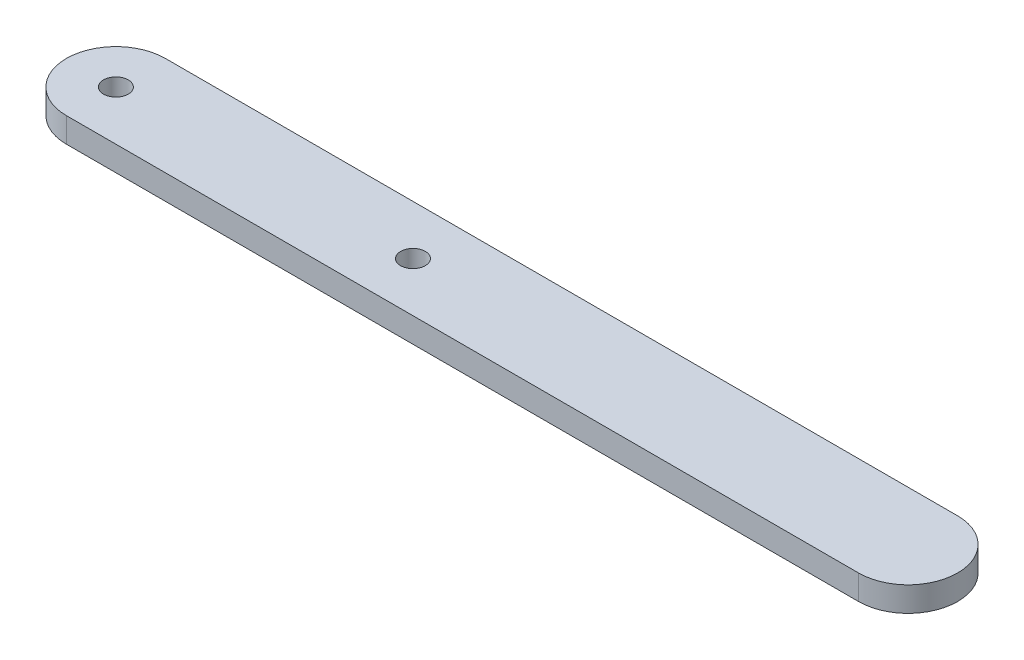
from build123d import *

# Parameters (mm, degrees)
SKETCH1_R           = 1.5875
BOSS_EXTRUDE1_DEPTH = 3.175


with BuildPart() as part:
    # Sketch1 → Boss-Extrude1 (new body)
    with BuildSketch(Plane(origin=(0, 0, 0), x_dir=(1, 0, 0), z_dir=(0, 1, 0))):
        with BuildLine():
            Line((0, 6.35), (101.6, 6.35))
            ThreePointArc((101.6, 6.35), (107.95, 0), (101.6, -6.35))
            Line((101.6, -6.35), (0, -6.35))
            ThreePointArc((0, -6.35), (-6.35, 0), (0, 6.35))
        make_face()
        Circle(SKETCH1_R, mode=Mode.SUBTRACT)
        with Locations((38.1, 0)):
            Circle(SKETCH1_R, mode=Mode.SUBTRACT)
    extrude(amount=BOSS_EXTRUDE1_DEPTH)


solid = part.part
